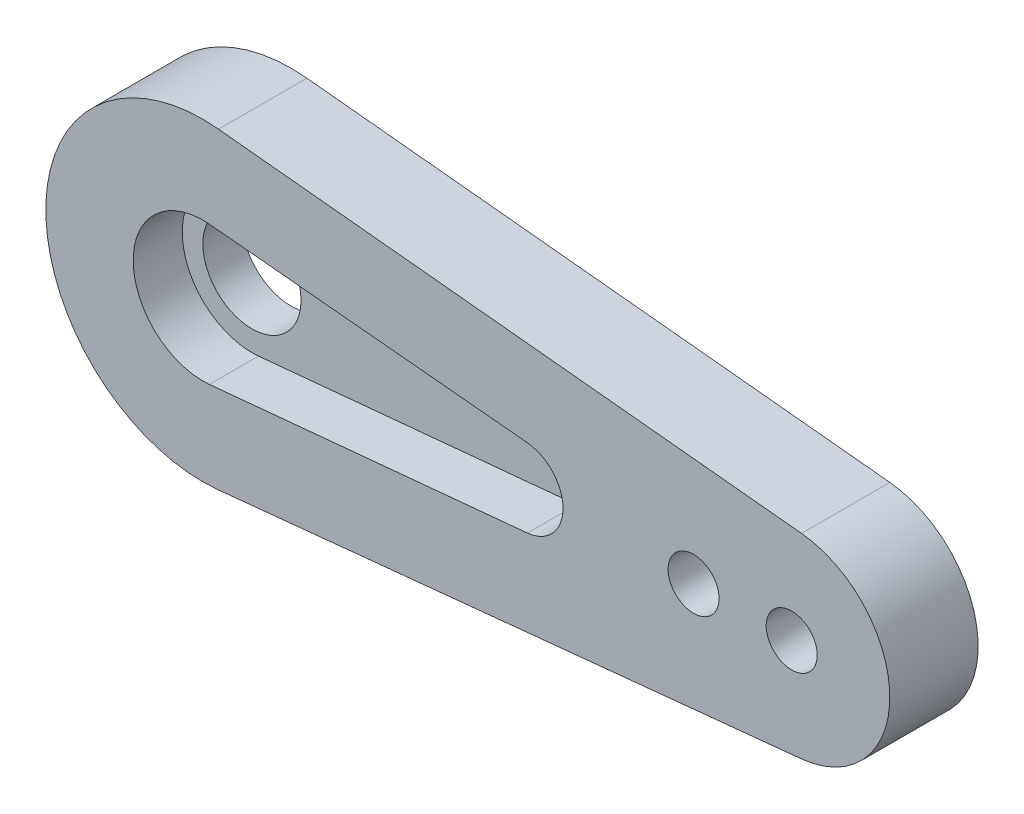
from build123d import *
from build123d.topology import SkipClean

# Parameters (mm, degrees)
MAIN_DEPTH            = 2.5
ESQUISSE2_R           = 2.5
ORIGINALBRACKET_DEPTH = 2
ESQUISSE3_R           = 1.3
FIXINGHOLE_DEPTH      = 37.183559803


with BuildPart() as part:
    # Esquisse1 → Main (new body)
    with BuildSketch(Plane.XY):
        with BuildLine():
            Line((0.8, 7.959899497), (30.5, 4.974937186))
            ThreePointArc((30.5, 4.974937186), (35, 0), (30.5, -4.974937186))
            Line((30.5, -4.974937186), (0.8, -7.959899497))
            ThreePointArc((0.8, -7.959899497), (-8, 0), (0.8, 7.959899497))
        make_face()
        with BuildLine():
            Line((0.336544343, 3.534011588), (16.539602446, 1.990992444))
            ThreePointArc((16.539602446, 1.990992444), (18.35, 0), (16.539602446, -1.990992444))
            Line((16.539602446, -1.990992444), (0.336544343, -3.534011588))
            ThreePointArc((0.336544343, -3.534011588), (-3.55, 0), (0.336544343, 3.534011588))
        make_face(mode=Mode.SUBTRACT)
    extrude(amount=MAIN_DEPTH)

    # Esquisse2 → OriginalBracket (add)
    with SkipClean():  # the faces are left unmerged after this step: merging them gives an invalid solid
        with BuildSketch(Plane(origin=(0, 0, 0), x_dir=(-1, 0, 0), z_dir=(0, 0, -1))):
            with BuildLine():
                Line((-0.8, -7.959899497), (-30.5, -4.974937186))
                ThreePointArc((-30.5, -4.974937186), (-35, 0), (-30.5, 4.974937186))
                Line((-30.5, 4.974937186), (-0.8, 7.959899497))
                ThreePointArc((-0.8, 7.959899497), (8, 0), (-0.8, -7.959899497))
            make_face()
            Circle(ESQUISSE2_R, mode=Mode.SUBTRACT)
        extrude(amount=ORIGINALBRACKET_DEPTH)

    # Esquisse3 → FixingHole (cut, through all)
    with SkipClean():  # the faces are left unmerged after this step: merging them gives an invalid solid
        with BuildSketch(Plane.XY.offset(2.5)):
            with Locations((30, 0)):
                Circle(ESQUISSE3_R)
            with Locations((25, 0)):
                Circle(ESQUISSE3_R)
        extrude(amount=-FIXINGHOLE_DEPTH, mode=Mode.SUBTRACT)


solid = part.part
